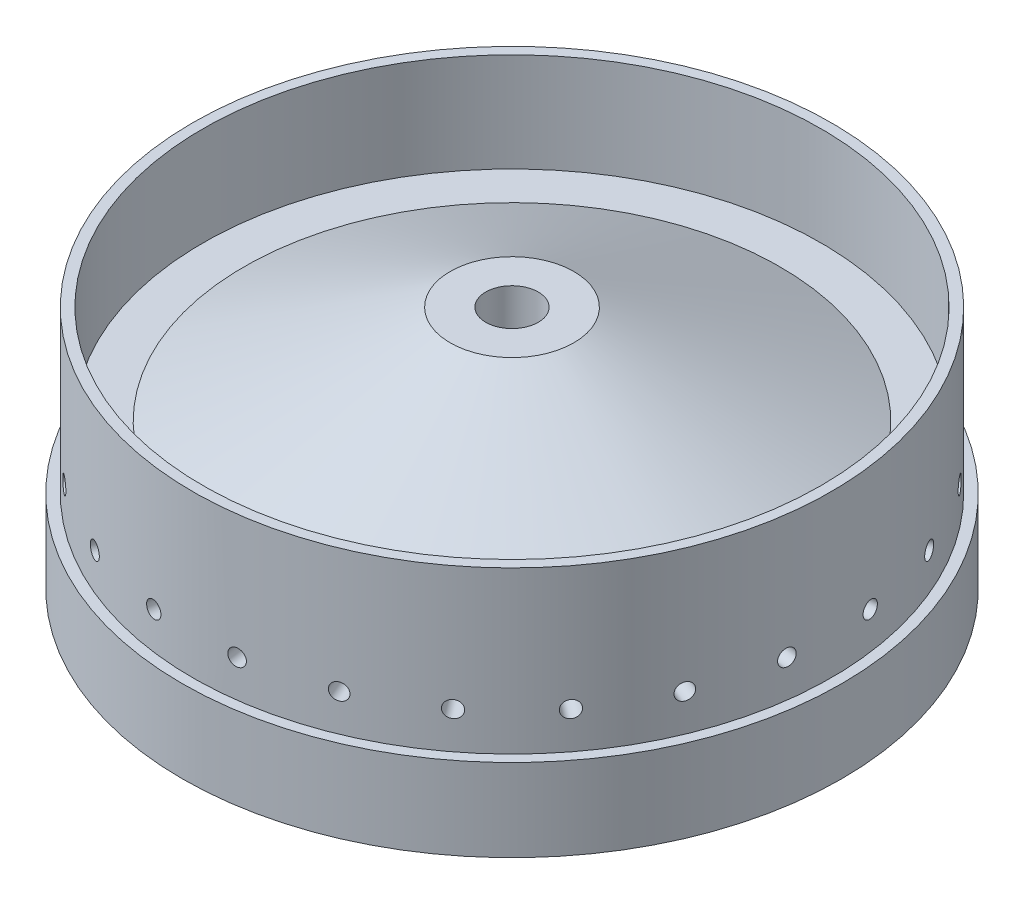
from build123d import *

# Parameters (mm, degrees)
CUT_EXTRUDE2_START    = 25.4
SKETCH3_R             = 101.6
SKETCH3_R_2           = 98.425
CUT_EXTRUDE2_DEPTH    = 50.68875
CIRPATTERN1_COUNT     = 24
BODY_MOVE_COPY1_ANGLE = 90


with BuildPart() as part:
    # Sketch1 → Revolve1 (revolve)
    with BuildSketch(Plane(origin=(0, 0, 0), x_dir=(1, 0, 0), z_dir=(0, 1, 0))):
        with BuildLine():
            add(Edge.make_bspline(
                [(95.25, 0), (95.25, 54.633955198), (8.09625, 59.277841389)],
                knots=[3.141592654, 3.141592654, 3.141592654, 4.627286292, 4.627286292, 4.627286292], degree=2, weights=[1, 0.736545993, 1]))
            Line((95.25, 0), (101.6, 0))
            Line((101.6, 0), (101.6, 59.49315))
            Line((101.6, 59.49315), (101.6, 75.08875))
            Line((101.6, 75.08875), (95.25, 75.08875))
            Line((95.25, 75.08875), (95.25, 44.60875))
            Line((95.25, 44.60875), (82.55, 44.60875))
            Line((82.55, 44.60875), (19.05, 75.08875))
            Line((19.05, 75.08875), (8.09625, 75.08875))
            Line((8.09625, 75.08875), (8.09625, 59.277841389))
        make_face()
    revolve(axis=Axis((0, 0, 0), (0, 0, -1)))

    # Sketch3 → Cut-Extrude2 (cut, through all)
    with BuildSketch(Plane(origin=(0, 0, 0), x_dir=(-1, 0, 0), z_dir=(0, 0, -1)).offset(CUT_EXTRUDE2_START)):
        Circle(SKETCH3_R)
        Circle(SKETCH3_R_2, mode=Mode.SUBTRACT)
    extrude(amount=CUT_EXTRUDE2_DEPTH, mode=Mode.SUBTRACT)

    # Sketch10 → 1/4-20 Tapped Hole1 (revolve, cut)
    with BuildSketch(Plane(origin=(97.582960481, 12.847040469, -36.83), x_dir=(-0.130526192, 0.991444861, 0), z_dir=(0, 0, 1))):
        Polygon((0, 0), (0, 14.233816902), (2.5527, 12.7), (2.5527, 0), align=None)
    f_1_4_20_tapped_hole1 = revolve(axis=Axis((103.87863535, 13.67588179, -36.83), (-0.991444861, -0.130526192, 0)), mode=Mode.SUBTRACT)

    # CirPattern1: 1/4-20 Tapped Hole1 ×24 about axis
    cirpattern1_axis = Axis((0, 0, 0), (0, 0, -1))
    for i in range(1, CIRPATTERN1_COUNT):
        add(f_1_4_20_tapped_hole1.rotate(cirpattern1_axis, i * 360 / CIRPATTERN1_COUNT), mode=Mode.SUBTRACT)


with BuildPart() as part_1:
    # Body-Move/Copy1: moved
    add(part.part.rotate(Axis((0, 0, -37.544375), (1, 0, 0)), BODY_MOVE_COPY1_ANGLE))


solid = part_1.part
